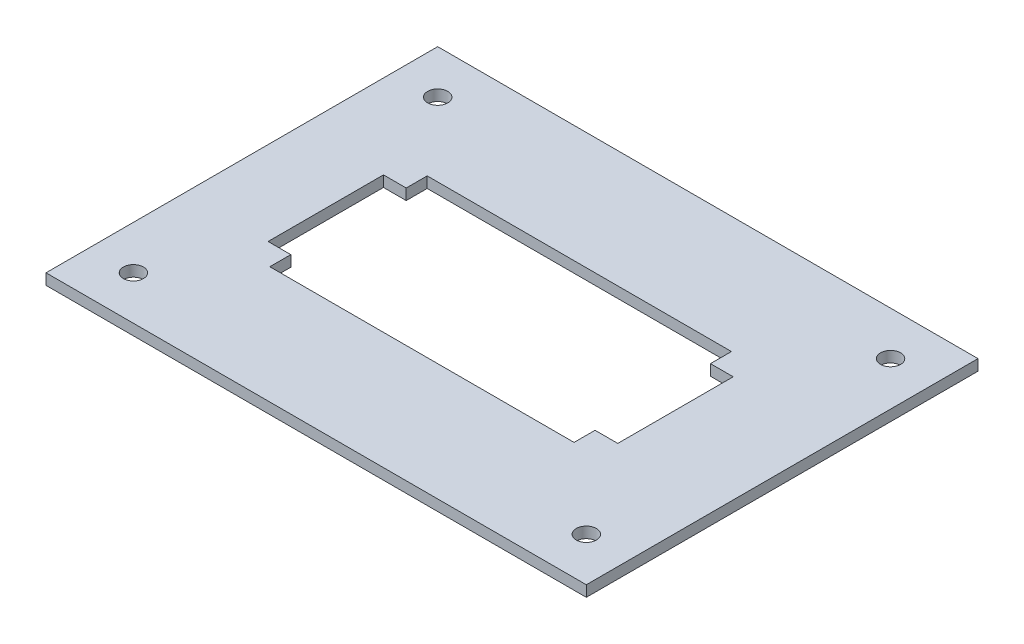
from build123d import *

# Parameters (mm, degrees)
SKETCH2_W           = 78.486
SKETCH2_H           = 56.896
BOSS_EXTRUDE1_DEPTH = 1.5875
SKETCH3_R           = 1.4605
CUT_EXTRUDE1_DEPTH  = 2.5875


with BuildPart() as part:
    # Sketch2 → Boss-Extrude1 (new body)
    with BuildSketch(Plane(origin=(0, 0, 0), x_dir=(1, 0, 0), z_dir=(0, 1, 0))):
        with Locations((39.243, 28.448)):
            Rectangle(SKETCH2_W, SKETCH2_H)
        Polygon((15.494, 39.878), (59.69, 39.878), (59.69, 36.83), (62.992, 36.83), (62.992, 20.066), (59.69, 20.066), (59.69, 17.018), (15.494, 17.018), (15.494, 20.066), (12.192, 20.066), (12.192, 36.83), (15.494, 36.83), align=None, mode=Mode.SUBTRACT)
    extrude(amount=BOSS_EXTRUDE1_DEPTH)

    # Sketch3 → Cut-Extrude1 (cut, through all)
    with BuildSketch(Plane(origin=(0, 1.5875, 0), x_dir=(1, 0, 0), z_dir=(0, 1, 0))):
        with Locations((6.35, 50.546)):
            Circle(SKETCH3_R)
        with Locations((6.35, 6.35)):
            Circle(SKETCH3_R)
        with Locations((72.136, 50.546)):
            Circle(SKETCH3_R)
        with Locations((72.136, 6.35)):
            Circle(SKETCH3_R)
    extrude(amount=-CUT_EXTRUDE1_DEPTH, mode=Mode.SUBTRACT)


solid = part.part
